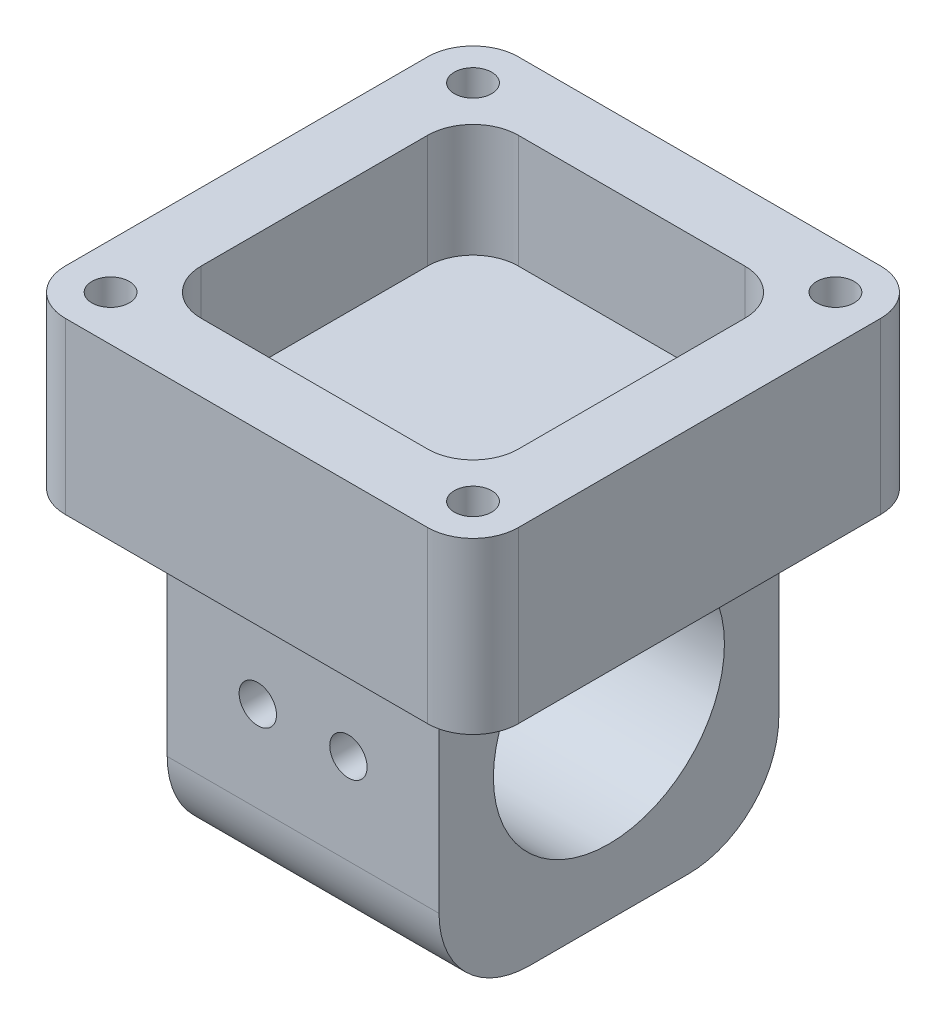
from build123d import *

# Parameters (mm, degrees)
SKETCH1_W           = 24
SKETCH1_H           = 30
BOSS_EXTRUDE1_DEPTH = 11
SKETCH2_R           = 1.65
CUT_EXTRUDE1_DEPTH  = 30
SKETCH3_R           = 10.2
CUT_EXTRUDE2_DEPTH  = 24
SKETCH5_W           = 40
SKETCH5_H           = 40
BOSS_EXTRUDE3_DEPTH = 5
SKETCH8_W           = 40
SKETCH8_H           = 40
SKETCH8_W_2         = 28
SKETCH8_H_2         = 28
BOSS_EXTRUDE4_DEPTH = 10
SKETCH9_R           = 1.65
CUT_EXTRUDE3_DEPTH  = 15
FILLET3_R           = 4
SKETCH10_W          = 24
SKETCH10_H          = 30
BOSS_EXTRUDE5_DEPTH = 5
FILLET6_R           = 8


with BuildPart() as part:
    # Sketch1 → Boss-Extrude1 (new body, symmetric)
    with BuildSketch(Plane(origin=(0, 0, 0), x_dir=(1, 0, 0), z_dir=(0, 1, 0))):
        Rectangle(SKETCH1_W, SKETCH1_H)
    extrude(amount=BOSS_EXTRUDE1_DEPTH, both=True)

    # Sketch2 → Cut-Extrude1 (cut)
    with BuildSketch(Plane(origin=(0, 0, -15), x_dir=(-1, 0, 0), z_dir=(0, 0, -1))):
        with Locations((4, 0)):
            Circle(SKETCH2_R)
        with Locations((-4, 0)):
            Circle(SKETCH2_R)
    extrude(amount=-CUT_EXTRUDE1_DEPTH, mode=Mode.SUBTRACT)

    # Sketch3 → Cut-Extrude2 (cut)
    with BuildSketch(Plane.ZY.offset(12)):
        Circle(SKETCH3_R)
    extrude(amount=-CUT_EXTRUDE2_DEPTH, mode=Mode.SUBTRACT)

    # Sketch5 → Boss-Extrude3 (add)
    with BuildSketch(Plane(origin=(0, 16, 0), x_dir=(1, 0, 0), z_dir=(0, 1, 0))):
        Rectangle(SKETCH5_W, SKETCH5_H)
    extrude(amount=-BOSS_EXTRUDE3_DEPTH)

    # Sketch8 → Boss-Extrude4 (add)
    with BuildSketch(Plane(origin=(0, 16, 0), x_dir=(1, 0, 0), z_dir=(0, 1, 0))):
        Rectangle(SKETCH8_W, SKETCH8_H)
        Rectangle(SKETCH8_W_2, SKETCH8_H_2, mode=Mode.SUBTRACT)
    extrude(amount=BOSS_EXTRUDE4_DEPTH)

    # Sketch9 → Cut-Extrude3 (cut)
    with BuildSketch(Plane(origin=(0, 26, 0), x_dir=(1, 0, 0), z_dir=(0, 1, 0))):
        with Locations((-16, 16)):
            Circle(SKETCH9_R)
        with Locations((16, 16)):
            Circle(SKETCH9_R)
        with Locations((16, -16)):
            Circle(SKETCH9_R)
        with Locations((-16, -16)):
            Circle(SKETCH9_R)
    extrude(amount=-CUT_EXTRUDE3_DEPTH, mode=Mode.SUBTRACT)

    # Fillet3
    fillet3_edges = [part.edges().sort_by_distance(p)[0] for p in [
        (20, 18.5, 20),
        (20, 18.5, -20),
        (-20, 18.5, -20),
        (-20, 18.5, 20),
        (-14, 21, 14),
        (-14, 21, -14),
        (14, 21, -14),
        (14, 21, 14),
    ]]
    fillet(fillet3_edges, radius=FILLET3_R)

    # Sketch10 → Boss-Extrude5 (add)
    with BuildSketch(Plane.XZ.offset(11)):
        Rectangle(SKETCH10_W, SKETCH10_H)
    extrude(amount=BOSS_EXTRUDE5_DEPTH)

    # Fillet6
    fillet6_edges = [part.edges().sort_by_distance(p)[0] for p in [
        (0, -16, 15),
        (0, -16, -15),
    ]]
    fillet(fillet6_edges, radius=FILLET6_R)


solid = part.part
